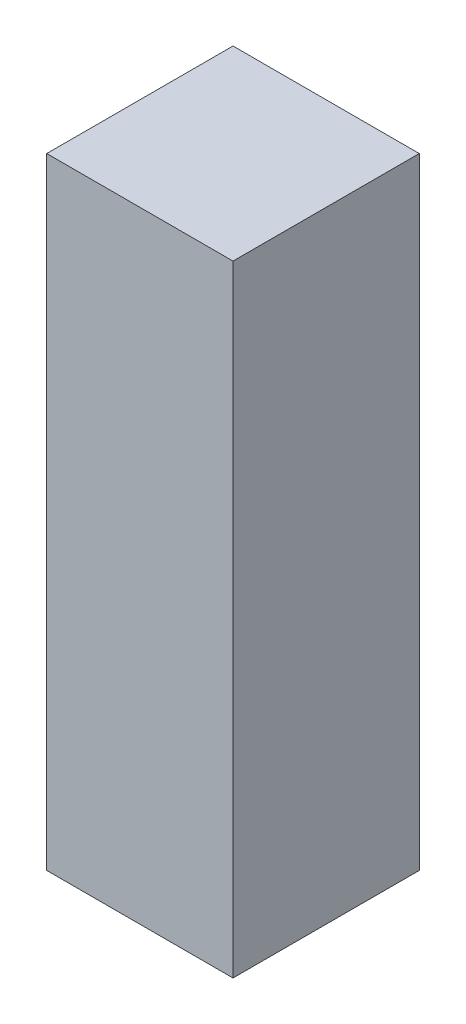
from build123d import *

# Parameters (mm, degrees)
SKETCH3_W           = 30
SKETCH3_H           = 100
BOSS_EXTRUDE1_DEPTH = 15


with BuildPart() as part:
    # Sketch3 → Boss-Extrude1 (new body, symmetric)
    with BuildSketch(Plane.XY):
        Rectangle(SKETCH3_W, SKETCH3_H)
    extrude(amount=BOSS_EXTRUDE1_DEPTH, both=True)


solid = part.part
